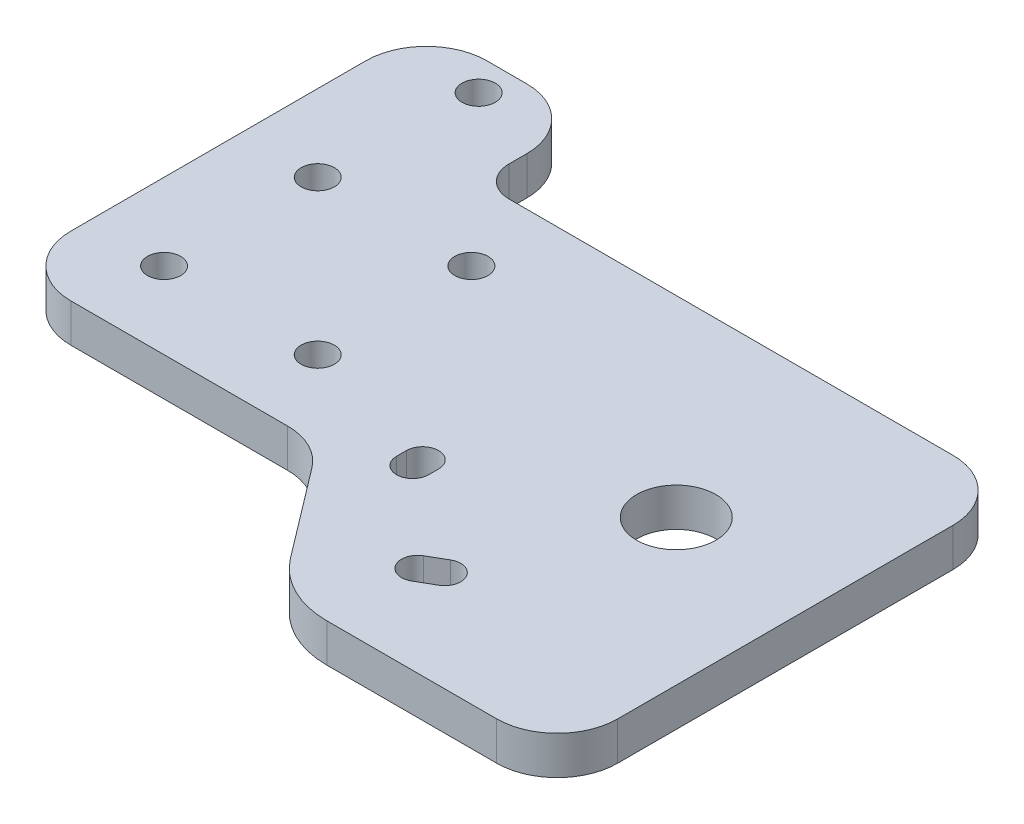
from build123d import *

# Parameters (mm, degrees)
BOSS_EXTRUDE1_DEPTH  = 6.35
M5_CLEARANCE_HOLE1_D = 5.5
CUT_EXTRUDE2_DEPTH   = 7.35
FILLET1_R            = 10
SKETCH10_R           = 6.55
CUT_EXTRUDE3_DEPTH   = 7.35
FILLET2_R            = 5


with BuildPart() as part:
    # Sketch1 → Boss-Extrude1 (new body)
    with BuildSketch(Plane(origin=(0, 0, 0), x_dir=(1, 0, 0), z_dir=(0, 1, 0))):
        with BuildLine():
            Line((25.4, -25.4), (-25.4, -25.4))
            Line((-25.4, -25.4), (-25.4, 25.4))
            Line((-25.4, 25.4), (-25.4, 43.35))
            Line((-25.4, 43.35), (1.2, 43.35))
            Line((1.2, 43.35), (1.2, 25.4))
            Line((1.2, 25.4), (25.4, 25.4))
            Line((25.4, 25.4), (89.621209859, 25.4))
            Line((89.621209859, 25.4), (89.621209859, -50.04))
            Line((89.621209859, -50.04), (51.541941751, -50.04))
            ThreePointArc((51.541941751, -50.04), (44.870841587, -48.474895705), (39.591870426, -44.10618968))
            Line((39.591870426, -44.10618968), (25.4, -25.4))
        make_face()
    extrude(amount=BOSS_EXTRUDE1_DEPTH)

    # M5 Clearance Hole1 (through all)
    with Locations(Plane(origin=(0, 6.35, 0), x_dir=(1, 0, 0), z_dir=(0, 1, 0))):
        with Locations((-12.7, 12.7), (12.7, 12.7), (12.7, -12.7), (-12.7, -12.7), (-11.5, 38.1)):
            Hole(M5_CLEARANCE_HOLE1_D / 2)

    # Sketch7 → Cut-Extrude2 (cut, through all)
    with BuildSketch(Plane(origin=(0, 6.35, 0), x_dir=(1, 0, 0), z_dir=(0, 1, 0))):
        with BuildLine():
            Line((53.051764766, -31.105892862), (50.215452987, -32.745892862))
            ThreePointArc((50.215452987, -32.745892862), (49.247834614, -36.366488764), (52.868430515, -37.334107138))
            Line((52.868430515, -37.334107138), (55.704742294, -35.694107138))
            ThreePointArc((55.704742294, -35.694107138), (56.672360668, -32.073511236), (53.051764766, -31.105892862))
        make_face()
        with BuildLine():
            Line((33.75, -19.08), (33.75, -20.72))
            ThreePointArc((33.75, -20.72), (36.4, -23.37), (39.05, -20.72))
            Line((39.05, -20.72), (39.05, -19.08))
            ThreePointArc((39.05, -19.08), (36.4, -16.43), (33.75, -19.08))
        make_face()
    extrude(amount=-CUT_EXTRUDE2_DEPTH, mode=Mode.SUBTRACT)

    # Fillet1
    fillet1_edges = [part.edges().sort_by_distance(p)[0] for p in [
        (-25.4, 3.175, -43.35),
        (1.2, 3.175, -43.35),
        (89.621209859, 3.175, -25.4),
        (89.621209859, 3.175, 50.04),
        (25.4, 3.175, 25.4),
        (-25.4, 3.175, 25.4),
    ]]
    fillet(fillet1_edges, radius=FILLET1_R)

    # Sketch10 → Cut-Extrude3 (cut, through all)
    with BuildSketch(Plane(origin=(0, 6.35, 0), x_dir=(1, 0, 0), z_dir=(0, 1, 0))):
        with Locations((65.621209859, -6.36)):
            Circle(SKETCH10_R)
    extrude(amount=-CUT_EXTRUDE3_DEPTH, mode=Mode.SUBTRACT)

    # Fillet2
    fillet2_edges = [part.edges().sort_by_distance(p)[0] for p in [
        (1.2, 3.175, -25.4),
    ]]
    fillet(fillet2_edges, radius=FILLET2_R)


solid = part.part
